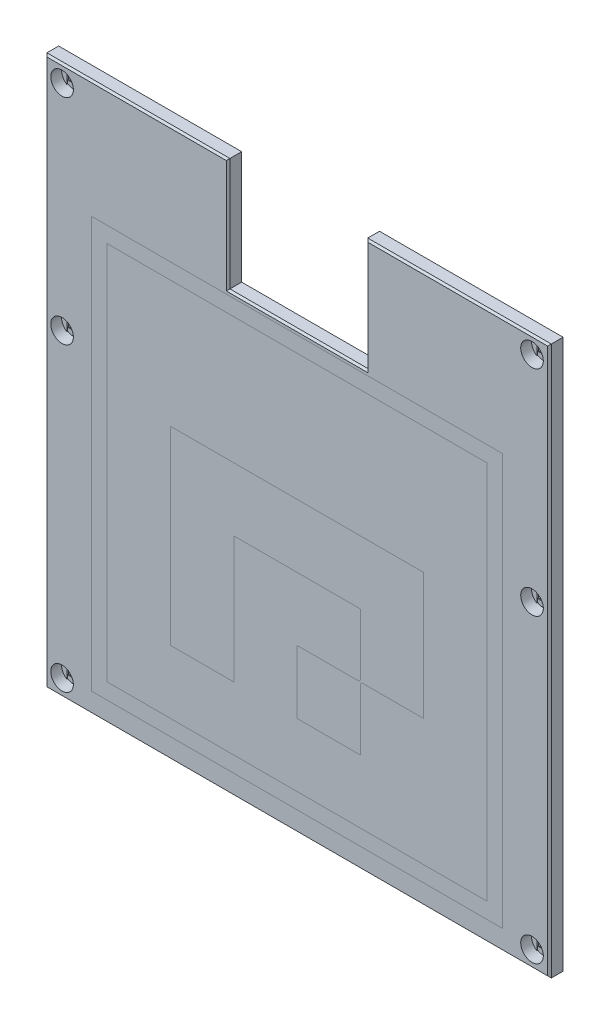
from build123d import *

# Parameters (mm, degrees)
SKETCH1_R           = 1.35
BOSS_EXTRUDE1_DEPTH = 3
SKETCH3_R           = 2.5
CUT_EXTRUDE1_DEPTH  = 2.4
SKETCH4_W           = 91.5
SKETCH4_H           = 85.5
CUT_EXTRUDE2_DEPTH  = 1.5
CUT_EXTRUDE3_DEPTH  = 0.2
SKETCH6_W           = 2.7
SKETCH6_H           = 2.7
CUT_EXTRUDE4_DEPTH  = 0.2
CHAMFER1_SIZE       = 0.4
SKETCH7_W           = 91
SKETCH7_H           = 91
CUT_EXTRUDE5_DEPTH  = 0.4
SKETCH8_W           = 91
SKETCH8_H           = 91
SKETCH8_W_2         = 84
SKETCH8_H_2         = 84
BOSS_EXTRUDE2_DEPTH = 0.4
CUT_EXTRUDE6_DEPTH  = 0.4
BOSS_EXTRUDE3_DEPTH = 0.4


with BuildPart() as part:
    # Sketch1 → Boss-Extrude1 (new body)
    with BuildSketch(Plane.XY):
        Polygon((-15.25, 53.75), (-15.25, 28.75), (15.25, 28.75), (15.25, 53.75), (55.875, 53.75), (55.875, -67.75), (-55.75, -67.75), (-55.75, 53.75), align=None)
        with Locations((-52, 50)):
            Circle(SKETCH1_R, mode=Mode.SUBTRACT)
        with Locations((-52, 2.6)):
            Circle(SKETCH1_R, mode=Mode.SUBTRACT)
        with Locations((-52, -64)):
            Circle(SKETCH1_R, mode=Mode.SUBTRACT)
        with Locations((52, 50)):
            Circle(SKETCH1_R, mode=Mode.SUBTRACT)
        with Locations((52, 2.6)):
            Circle(SKETCH1_R, mode=Mode.SUBTRACT)
        with Locations((52, -64)):
            Circle(SKETCH1_R, mode=Mode.SUBTRACT)
    extrude(amount=BOSS_EXTRUDE1_DEPTH)

    # Sketch3 → Cut-Extrude1 (cut)
    with BuildSketch(Plane.XY.offset(3)):
        with Locations((-52, 50)):
            Circle(SKETCH3_R)
        with Locations((-52, 2.6)):
            Circle(SKETCH3_R)
        with Locations((-52, -64)):
            Circle(SKETCH3_R)
        with Locations((52, -64)):
            Circle(SKETCH3_R)
        with Locations((52, 2.6)):
            Circle(SKETCH3_R)
        with Locations((52, 50)):
            Circle(SKETCH3_R)
    extrude(amount=-CUT_EXTRUDE1_DEPTH, mode=Mode.SUBTRACT)

    # Sketch4 → Cut-Extrude2 (cut)
    with BuildSketch(Plane(origin=(0, 0, 0), x_dir=(-1, 0, 0), z_dir=(0, 0, -1))):
        with Locations((0, -15)):
            Rectangle(SKETCH4_W, SKETCH4_H)
    extrude(amount=-CUT_EXTRUDE2_DEPTH, mode=Mode.SUBTRACT)

    # Sketch5 → Cut-Extrude3 (cut)
    with BuildSketch(Plane.XY.offset(0.6)):
        with BuildLine():
            Line((-53.35, 47.895837459), (-53.35, 52.104162541))
            ThreePointArc((-53.35, 52.104162541), (-52, 52.5), (-50.65, 52.104162541))
            Line((-50.65, 52.104162541), (-50.65, 47.895837459))
            ThreePointArc((-50.65, 47.895837459), (-52, 47.5), (-53.35, 47.895837459))
        make_face()
        with BuildLine():
            Line((-53.35, 0.495837459), (-53.35, 4.704162541))
            ThreePointArc((-53.35, 4.704162541), (-52, 5.1), (-50.65, 4.704162541))
            Line((-50.65, 4.704162541), (-50.65, 0.495837459))
            ThreePointArc((-50.65, 0.495837459), (-52, 0.1), (-53.35, 0.495837459))
        make_face()
        with BuildLine():
            Line((-53.35, -66.104162541), (-53.35, -61.895837459))
            ThreePointArc((-53.35, -61.895837459), (-52, -61.5), (-50.65, -61.895837459))
            Line((-50.65, -61.895837459), (-50.65, -66.104162541))
            ThreePointArc((-50.65, -66.104162541), (-52, -66.5), (-53.35, -66.104162541))
        make_face()
    cut_extrude3 = extrude(amount=-CUT_EXTRUDE3_DEPTH, mode=Mode.SUBTRACT)

    # Sketch6 → Cut-Extrude4 (cut)
    with BuildSketch(Plane.XY.offset(0.4)):
        with Locations((-52, -64)):
            Rectangle(SKETCH6_W, SKETCH6_H)
        with Locations((-52, 2.6)):
            Rectangle(SKETCH6_W, SKETCH6_H)
        with Locations((-52, 50)):
            Rectangle(SKETCH6_W, SKETCH6_H)
    cut_extrude4 = extrude(amount=-CUT_EXTRUDE4_DEPTH, mode=Mode.SUBTRACT)

    # Mirror1: Cut-Extrude3, Cut-Extrude4 across plane
    add(cut_extrude3.mirror(Plane(origin=(0, 0, 0), x_dir=(0, 0, 1), z_dir=(1, 0, 0))), mode=Mode.SUBTRACT)
    add(cut_extrude4.mirror(Plane(origin=(0, 0, 0), x_dir=(0, 0, 1), z_dir=(1, 0, 0))), mode=Mode.SUBTRACT)

    # Chamfer1
    chamfer1_edges = [part.edges().sort_by_distance(p)[0] for p in [
        (55.875, -7, 3),
        (35.5625, 53.75, 3),
        (15.25, 41.25, 3),
        (0, 28.75, 3),
        (-15.25, 41.25, 3),
        (-35.5, 53.75, 3),
        (-55.75, -7, 3),
        (0.0625, -67.75, 3),
    ]]
    chamfer(chamfer1_edges, length=CHAMFER1_SIZE)

    # Sketch7 → Cut-Extrude5 (cut)
    with BuildSketch(Plane.XY.offset(3)):
        with Locations((0, -17.75)):
            Rectangle(SKETCH7_W, SKETCH7_H)
        Polygon((28, 24.25), (42, 24.25), (42, 10.25), (42, -3.75), (42, -17.75), (42, -31.75), (42, -45.75), (42, -59.75), (28, -59.75), (14, -59.75), (0, -59.75), (-14, -59.75), (-28, -59.75), (-42, -59.75), (-42, -45.75), (-42, -31.75), (-42, -17.75), (-42, -3.75), (-42, 10.25), (-42, 24.25), (-28, 24.25), (-14, 24.25), (0, 24.25), (14, 24.25), align=None, mode=Mode.SUBTRACT)
    extrude(amount=-CUT_EXTRUDE5_DEPTH, mode=Mode.SUBTRACT)

    # Sketch9 → Cut-Extrude6 (cut)
    with BuildSketch(Plane.XY.offset(3)):
        Polygon((0, -45.75), (0, -31.75), (13.646446609, -31.75), (14, -31.396446609), (14, -17.75), (0, -17.75), (-14, -17.75), (-14, -31.75), (-14, -45.75), (-28, -45.75), (-28, -31.75), (-28, -17.75), (-28, -3.75), (-14, -3.75), (0, -3.75), (14, -3.75), (28, -3.75), (28, -17.75), (28, -31.75), (14.353553391, -31.75), (14, -32.103553391), (14, -45.75), align=None)
    extrude(amount=-CUT_EXTRUDE6_DEPTH, mode=Mode.SUBTRACT)


with BuildPart() as body_2:
    # Sketch8 → Boss-Extrude2 (new body)
    with BuildSketch(Plane.XY.offset(2.6)):
        with Locations((0, -17.75)):
            Rectangle(SKETCH8_W, SKETCH8_H)
        with Locations((0, -17.75)):
            Rectangle(SKETCH8_W_2, SKETCH8_H_2, mode=Mode.SUBTRACT)
    extrude(amount=BOSS_EXTRUDE2_DEPTH)


with BuildPart() as body_3:
    # Sketch10 → Boss-Extrude3 (new body)
    with BuildSketch(Plane.XY.offset(2.6)):
        Polygon((14, -32.103553391), (14.353553391, -31.75), (28, -31.75), (28, -3.75), (-28, -3.75), (-28, -45.75), (-14, -45.75), (-14, -17.75), (14, -17.75), (14, -31.396446609), (13.646446609, -31.75), (0, -31.75), (0, -45.75), (14, -45.75), align=None)
    extrude(amount=BOSS_EXTRUDE3_DEPTH)


solid = Compound([part.part, body_2.part, body_3.part])
